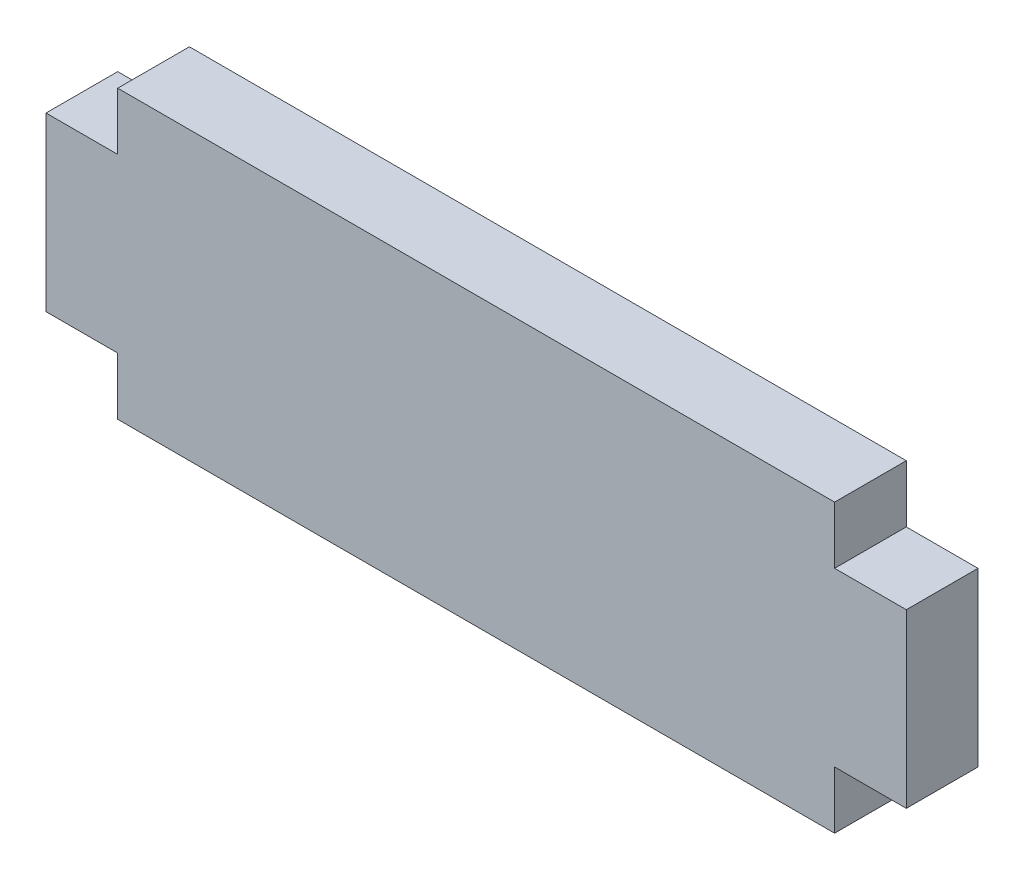
from build123d import *

# Parameters (mm, degrees)
SKETCH1_W           = 31.75
SKETCH1_H           = 12.7
BOSS_EXTRUDE1_DEPTH = 3.175
SKETCH2_W           = 3.175
SKETCH2_H           = 7.62
BOSS_EXTRUDE2_DEPTH = 3.175


with BuildPart() as part:
    # Sketch1 → Boss-Extrude1 (new body)
    with BuildSketch(Plane.XY):
        with Locations((15.875, 6.35)):
            Rectangle(SKETCH1_W, SKETCH1_H)
    extrude(amount=BOSS_EXTRUDE1_DEPTH)

    # Sketch2 → Boss-Extrude2 (add)
    with BuildSketch(Plane.XY.offset(3.175)):
        with Locations((-1.5875, 6.35)):
            Rectangle(SKETCH2_W, SKETCH2_H)
        with Locations((33.3375, 6.35)):
            Rectangle(SKETCH2_W, SKETCH2_H)
    extrude(amount=-BOSS_EXTRUDE2_DEPTH)


solid = part.part
